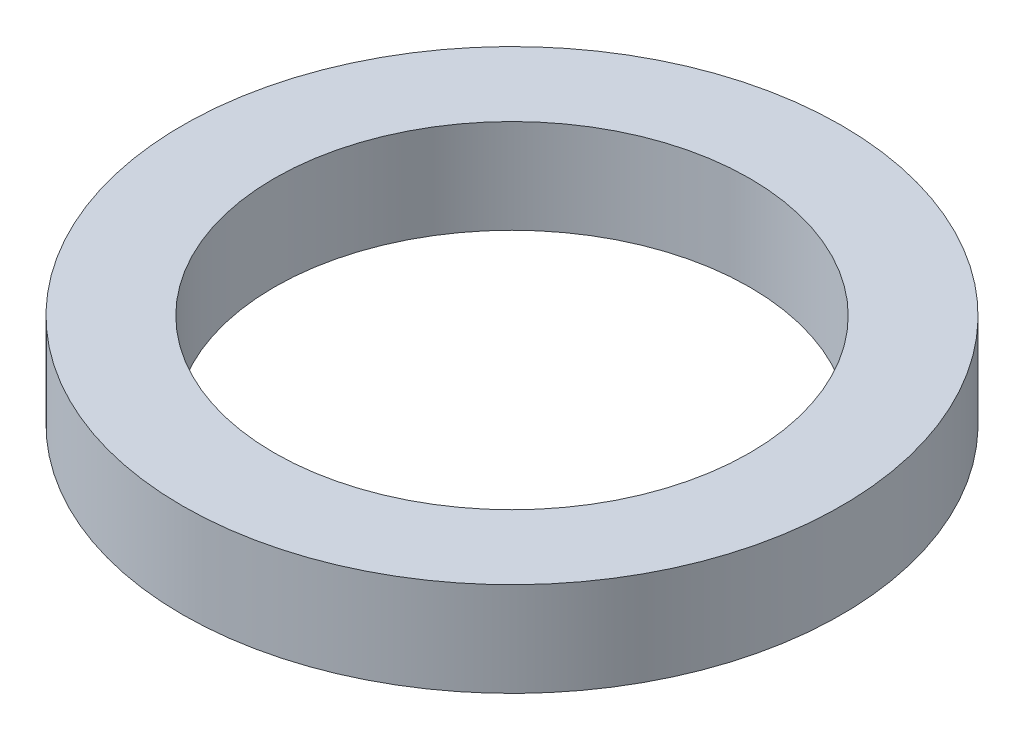
from build123d import *

# Parameters (mm, degrees)
SKETCH1_R           = 3.5
SKETCH1_R_2         = 2.525
BOSS_EXTRUDE1_DEPTH = 1


with BuildPart() as part:
    # Sketch1 → Boss-Extrude1 (new body)
    with BuildSketch(Plane(origin=(0, 0, 0), x_dir=(1, 0, 0), z_dir=(0, 1, 0))):
        Circle(SKETCH1_R)
        Circle(SKETCH1_R_2, mode=Mode.SUBTRACT)
    extrude(amount=BOSS_EXTRUDE1_DEPTH)


solid = part.part
